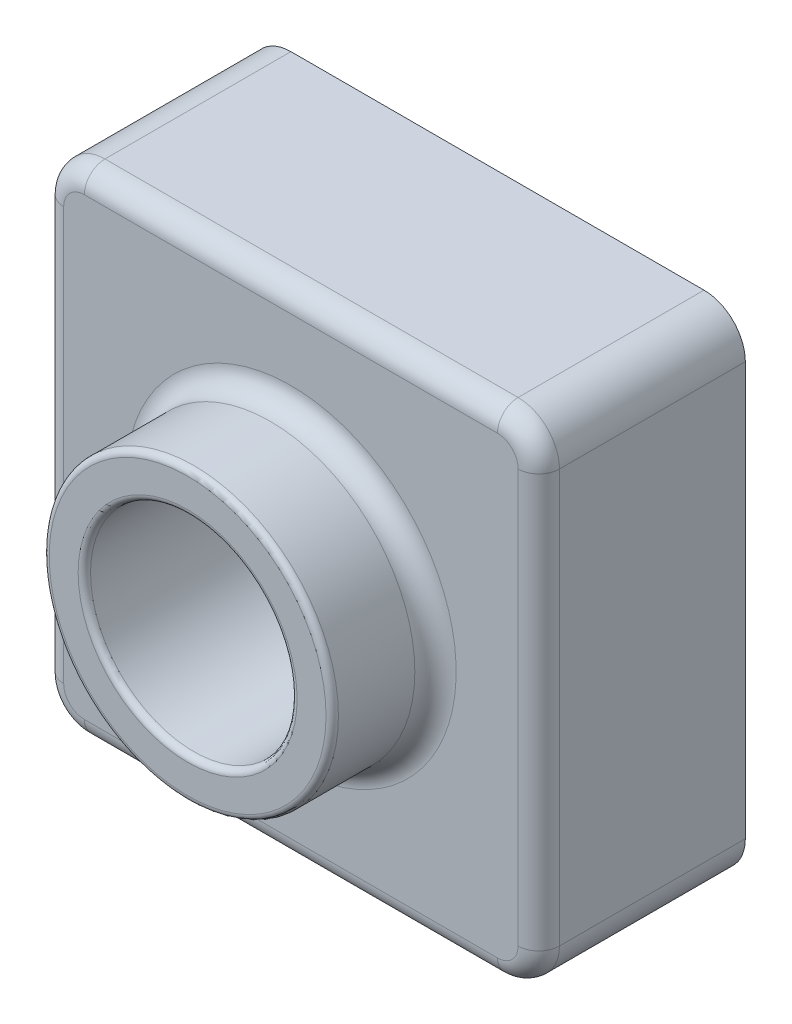
from build123d import *

# Parameters (mm, degrees)
SKETCH1_W           = 120
SKETCH1_H           = 120
BOSS_EXTRUDE1_DEPTH = 50
SKETCH2_R           = 35
BOSS_EXTRUDE2_DEPTH = 25
SKETCH3_R           = 25
CUT_EXTRUDE1_DEPTH  = 76
FILLET1_R           = 1.5
FILLET2_R           = 10
FILLET4_R           = 5
SHELL1_T            = -2


with BuildPart() as part:
    # Sketch1 → Boss-Extrude1 (new body)
    with BuildSketch(Plane.XY):
        Rectangle(SKETCH1_W, SKETCH1_H)
    extrude(amount=BOSS_EXTRUDE1_DEPTH)

    # Sketch2 → Boss-Extrude2 (add)
    with BuildSketch(Plane.XY.offset(50)):
        Circle(SKETCH2_R)
    extrude(amount=BOSS_EXTRUDE2_DEPTH)

    # Sketch3 → Cut-Extrude1 (cut, through all)
    with BuildSketch(Plane.XY.offset(75)):
        Circle(SKETCH3_R)
    extrude(amount=-CUT_EXTRUDE1_DEPTH, mode=Mode.SUBTRACT)

    # Fillet1
    fillet1_edges = [part.edges().sort_by_distance(p)[0] for p in [
        (-35, 0, 75),
        (-25, 0, 75),
    ]]
    fillet(fillet1_edges, radius=FILLET1_R)

    # Fillet2
    fillet2_edges = [part.edges().sort_by_distance(p)[0] for p in [
        (60, -60, 25),
        (-60, -60, 25),
        (-60, 60, 25),
        (60, 60, 25),
    ]]
    fillet(fillet2_edges, radius=FILLET2_R)

    # Fillet4
    fillet4_edges = [part.edges().sort_by_distance(p)[0] for p in [
        (-35, 0, 50),
        (0, -60, 50),
        (-60, 0, 50),
        (60, 0, 50),
        (0, 60, 50),
        (57.071067812, 57.071067812, 50),
        (57.071067812, -57.071067812, 50),
        (-57.071067812, 57.071067812, 50),
        (-57.071067812, -57.071067812, 50),
    ]]
    fillet(fillet4_edges, radius=FILLET4_R)

    # Shell1
    shell1_openings = [part.faces().sort_by_distance(p)[0] for p in [
        (25, 0, 0),
    ]]
    offset(amount=SHELL1_T, openings=shell1_openings, kind=Kind.INTERSECTION)


solid = part.part
